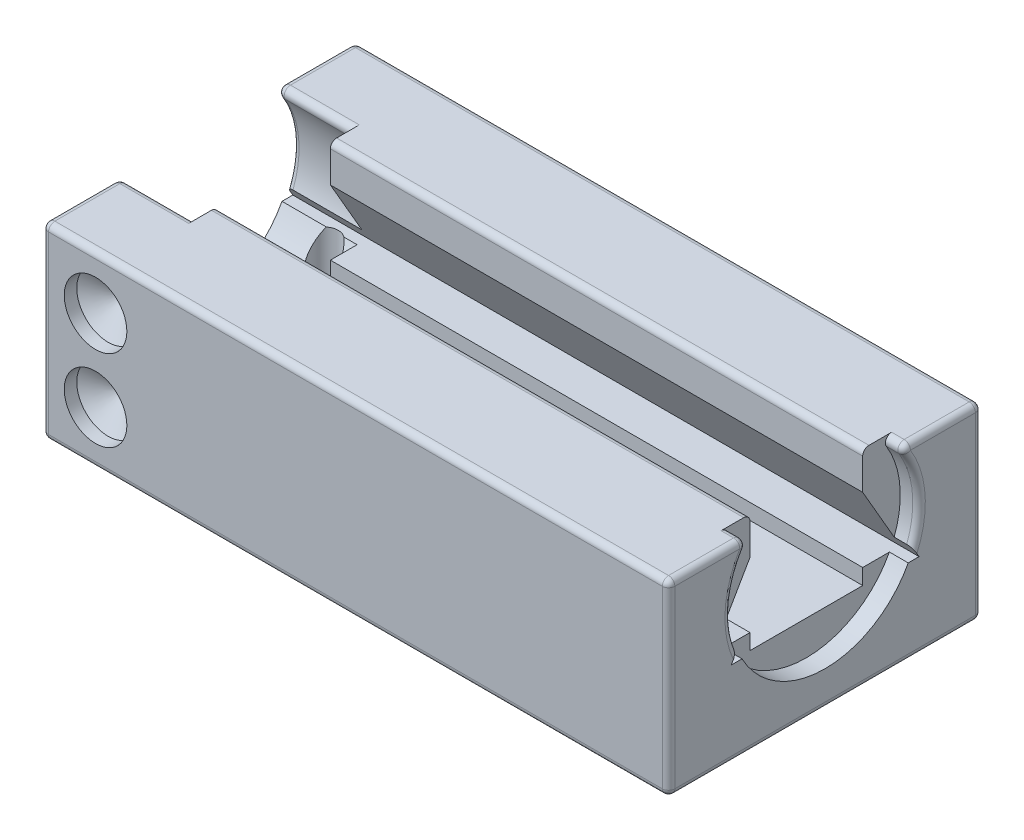
from build123d import *

# Parameters (mm, degrees)
SKETCH1_W                      = 10
SKETCH1_H                      = 5
BOSS_EXTRUDE1_DEPTH            = 3
CUT_EXTRUDE9_DEPTH             = 11
SKETCH20_R                     = 1.5
CUT_EXTRUDE11_DEPTH            = 1.2
SKETCH22_R                     = 1.5
SKETCH22_R_2                   = 0.55
CUT_EXTRUDE12_DEPTH            = 0.3
FILLET1_R                      = 0.1
FILLET2_R                      = 0.1
F_1_0MM_DOWEL_HOLE1_AT_2_COUNT = 2
F_1_0MM_DOWEL_HOLE1_AT_2_PITCH = 1.3


with BuildPart() as part:
    # Sketch1 → Boss-Extrude1 (new body)
    with BuildSketch(Plane(origin=(0, 4, 0), x_dir=(-1, 0, 0), z_dir=(0, 1, 0))):
        with Locations((-5, 2.5)):
            Rectangle(SKETCH1_W, SKETCH1_H)
    extrude(amount=-BOSS_EXTRUDE1_DEPTH)

    # Sketch18 → Cut-Extrude9 (cut, through all)
    with BuildSketch(Plane(origin=(10, 0, 0), x_dir=(0, 0, -1), z_dir=(1, 0, 0))):
        Polygon((-3.4, 3.4), (-4, 2.360769515), (-3.4, 2.360769515), (-3.4, 2.110769515), (-1.6, 2.110769515), (-1.6, 2.360769515), (-1, 2.360769515), (-1.6, 3.4), (-1.6, 4), (-3.4, 4), align=None)
    extrude(amount=-CUT_EXTRUDE9_DEPTH, mode=Mode.SUBTRACT)

    # Sketch20 → Cut-Extrude11 (cut)
    with BuildSketch(Plane.ZY):
        with Locations((2.5, 3.060769515)):
            Circle(SKETCH20_R)
    extrude(amount=-CUT_EXTRUDE11_DEPTH, mode=Mode.SUBTRACT)

    # Sketch22 → Cut-Extrude12 (cut)
    with BuildSketch(Plane(origin=(10, 0, 0), x_dir=(0, 0, -1), z_dir=(1, 0, 0))):
        with Locations((-2.5, 3.060769515)):
            Circle(SKETCH22_R)
        with Locations((-2.5, 3.060769515)):
            Circle(SKETCH22_R_2, mode=Mode.SUBTRACT)
    extrude(amount=-CUT_EXTRUDE12_DEPTH, mode=Mode.SUBTRACT)

    # Fillet1
    fillet1_edges = [part.edges().sort_by_distance(p)[0] for p in [
        (5, 1, 5),
        (5, 1, 0),
        (5, 4, 5),
        (5.45, 4, 1.6),
        (5.45, 4, 3.4),
        (5, 4, 0),
        (0.6, 4, 3.669549527),
        (0.6, 4, 1.330450473),
        (9.85, 4, 3.669549527),
        (9.85, 4, 1.330450473),
    ]]
    fillet(fillet1_edges, radius=FILLET1_R)

    # Fillet2
    fillet2_edges = [part.edges().sort_by_distance(p)[0] for p in [
        (10, 3.203038233, 1.006762038),
        (10, 3.203038233, 3.993237962),
        (10, 4, 4.381118968),
        (10, 2.5, 5),
        (10, 1, 2.5),
        (10, 2.5, 0),
        (10, 4, 0.618881032),
        (10, 3.970710678, 4.970710678),
        (10, 3.970710678, 0.029289322),
        (10, 1.029289322, 0.029289322),
        (10, 1.029289322, 4.970710678),
        (10, 3.948758638, 1.22506954),
        (10, 3.948758638, 3.77493046),
        (0, 4, 4.381118968),
        (0, 4, 0.618881032),
        (0, 3.203038233, 1.006762038),
        (0, 2.5, 0),
        (0, 1, 2.5),
        (0, 2.5, 5),
        (0, 3.970710678, 4.970710678),
        (0, 3.970710678, 0.029289322),
        (0, 1.029289322, 0.029289322),
        (0, 1.029289322, 4.970710678),
        (0, 3.948758638, 1.22506954),
        (0, 3.948758638, 3.77493046),
        (0, 3.203038233, 3.993237962),
    ]]
    fillet(fillet2_edges, radius=FILLET2_R)

    # Sketch26 → Ø1.0mm Dowel Hole1 (revolve, cut)
    with BuildSketch(Plane(origin=(0.85, 3.15, 5), x_dir=(0, -1, 0), z_dir=(1, 0, 0))):
        Polygon((0, 0), (0, 0.50043031), (0.5, 0.2), (0.5, 0), align=None)
    f_1_0mm_dowel_hole1 = revolve(axis=Axis((0.85, 3.15, 11.35), (0, 0, -1)), mode=Mode.SUBTRACT)

    # Ø1.0mm Dowel Hole1 at 2: Ø1.0mm Dowel Hole1 ×2
    with Locations(*[(0, -i * F_1_0MM_DOWEL_HOLE1_AT_2_PITCH, 0) for i in range(1, F_1_0MM_DOWEL_HOLE1_AT_2_COUNT)]):
        add(f_1_0mm_dowel_hole1, mode=Mode.SUBTRACT)

    # Sketch28 → UNM0.6 Tapped Hole1 (revolve, cut)
    with BuildSketch(Plane(origin=(0.85, 1, 3.65), x_dir=(0, 0, -1), z_dir=(1, 0, 0))):
        Polygon((0, 0), (0, 2.085193639), (0.225, 1.95), (0.225, 0), align=None)
    unm0_6_tapped_hole1 = revolve(axis=Axis((0.85, -5.35, 3.65), (0, 1, 0)), mode=Mode.SUBTRACT)

    # Mirror1: Ø1.0mm Dowel Hole1, UNM0.6 Tapped Hole1 across plane
    add(f_1_0mm_dowel_hole1.mirror(Plane(origin=(0, 0, 2.5), x_dir=(1, 0, 0), z_dir=(0, 0, -1))), mode=Mode.SUBTRACT)
    add(unm0_6_tapped_hole1.mirror(Plane(origin=(0, 0, 2.5), x_dir=(1, 0, 0), z_dir=(0, 0, -1))), mode=Mode.SUBTRACT)

    # Mirror1 copy 1 sketch → Mirror1 copy 1 (revolve, cut)
    with BuildSketch(Plane(origin=(0.85, 1.85, 0), x_dir=(0, -1, 0), z_dir=(1, 0, 0))):
        Polygon((0, 0), (0, -0.50043031), (0.5, -0.2), (0.5, 0), align=None)
    revolve(axis=Axis((0.85, 1.85, -6.35), (0, 0, -1)), mode=Mode.SUBTRACT)


solid = part.part
